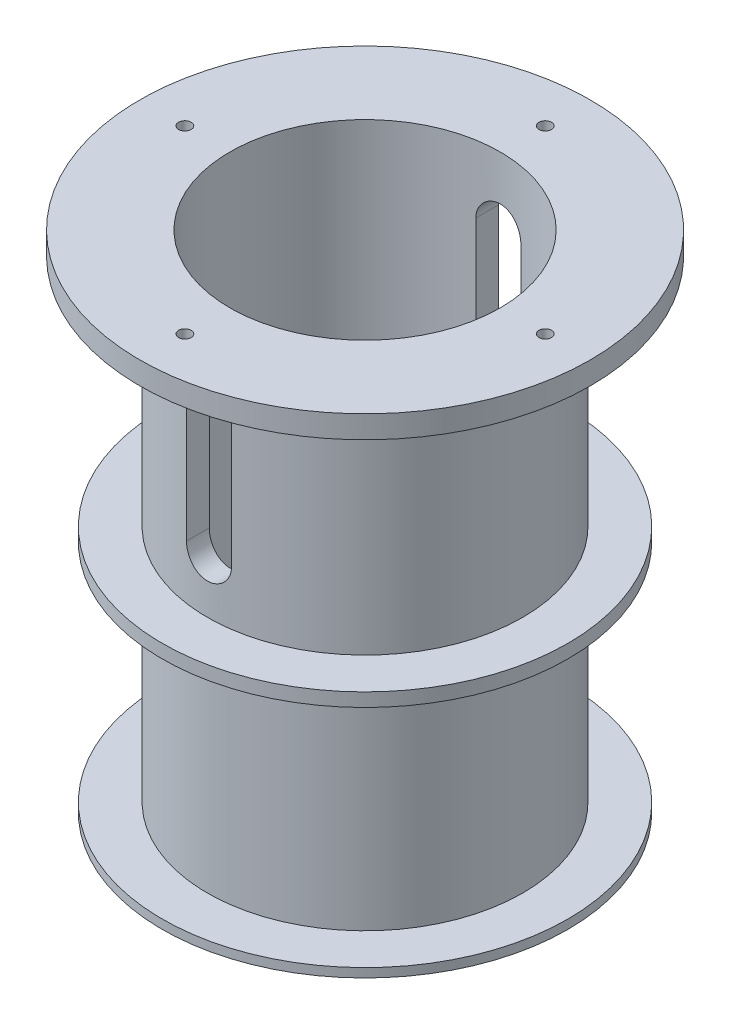
from build123d import *

# Parameters (mm, degrees)
SKETCH_2_R               = 35
SKETCH_2_R_2             = 30
EXTRUDE_1_DEPTH          = 50
SKETCH_3_R               = 45
SKETCH_3_R_2             = 30
EXTRUDE_2_DEPTH          = 2
CUT_EXTRUDE_1_REACH      = 134.454
SKETCH_4_R               = 1.4
CUT_EXTRUDE_2_DEPTH      = 93.736184955
CUT_EXTRUDE_2_DEPTH_BACK = 93.736184955


with BuildPart() as part:
    # 草图1 → 旋转1 (revolve)
    with BuildSketch(Plane.XY, mode=Mode.PRIVATE) as revolve_1_sk:
        Polygon((-45, 0), (-30, 0), (-30, 60), (-50, 60), (-50, 55), (-35, 55), (-35, 3), (-45, 3), align=None)
    revolve(revolve_1_sk.sketch.rotate(Axis((0, -563.187180309, 0), (0, 1, 0)), 180), axis=Axis((0, -563.187180309, 0), (0, 1, 0)))

    # 草图2 → 凸台-拉伸1 (add)
    with BuildSketch(Plane.XZ):
        Circle(SKETCH_2_R)
        Circle(SKETCH_2_R_2, mode=Mode.SUBTRACT)
    extrude(amount=EXTRUDE_1_DEPTH)

    # 草图3 → 凸台-拉伸2 (add)
    with BuildSketch(Plane.XZ.offset(50)):
        Circle(SKETCH_3_R)
        Circle(SKETCH_3_R_2, mode=Mode.SUBTRACT)
    extrude(amount=EXTRUDE_2_DEPTH)

    # 草图4 → 切除-拉伸1 (cut, up to next)
    with BuildSketch(Plane(origin=(0, 60, 0), x_dir=(1, 0, 0), z_dir=(0, 1, 0)), mode=Mode.PRIVATE) as cut_extrude_1_sk1:
        with Locations(Location((0, 40, 0), (0, 0, 180))):
            Circle(SKETCH_4_R)
    cut_extrude_1_tool1 = extrude(cut_extrude_1_sk1.sketch, amount=-CUT_EXTRUDE_1_REACH, mode=Mode.PRIVATE) & part.part
    # 草图4 → 切除-拉伸1 (cut, up to next)
    with BuildSketch(Plane(origin=(0, 60, 0), x_dir=(1, 0, 0), z_dir=(0, 1, 0)), mode=Mode.PRIVATE) as cut_extrude_1_sk2:
        with Locations(Location((40, 0, 0), (0, 0, 180))):
            Circle(SKETCH_4_R)
    cut_extrude_1_tool2 = extrude(cut_extrude_1_sk2.sketch, amount=-CUT_EXTRUDE_1_REACH, mode=Mode.PRIVATE) & part.part
    # 草图4 → 切除-拉伸1 (cut, up to next)
    with BuildSketch(Plane(origin=(0, 60, 0), x_dir=(1, 0, 0), z_dir=(0, 1, 0)), mode=Mode.PRIVATE) as cut_extrude_1_sk3:
        with Locations(Location((0, -40, 0), (0, 0, 180))):
            Circle(SKETCH_4_R)
    cut_extrude_1_tool3 = extrude(cut_extrude_1_sk3.sketch, amount=-CUT_EXTRUDE_1_REACH, mode=Mode.PRIVATE) & part.part
    # 草图4 → 切除-拉伸1 (cut, up to next)
    with BuildSketch(Plane(origin=(0, 60, 0), x_dir=(1, 0, 0), z_dir=(0, 1, 0)), mode=Mode.PRIVATE) as cut_extrude_1_sk4:
        with Locations(Location((-40, 0, 0), (0, 0, 180))):
            Circle(SKETCH_4_R)
    cut_extrude_1_tool4 = extrude(cut_extrude_1_sk4.sketch, amount=-CUT_EXTRUDE_1_REACH, mode=Mode.PRIVATE) & part.part
    add(cut_extrude_1_tool1.solids().sort_by_distance((0, 60, -40))[0], mode=Mode.SUBTRACT)
    add(cut_extrude_1_tool2.solids().sort_by_distance((40, 60, 0))[0], mode=Mode.SUBTRACT)
    add(cut_extrude_1_tool3.solids().sort_by_distance((0, 60, 40))[0], mode=Mode.SUBTRACT)
    add(cut_extrude_1_tool4.solids().sort_by_distance((-40, 60, 0))[0], mode=Mode.SUBTRACT)

    # 草图5 → 切除-拉伸2 (cut, two sides)
    with BuildSketch(Plane.XY) as cut_extrude_2_sk:
        with BuildLine():
            Line((5, 45), (5, 15))
            ThreePointArc((5, 15), (0, 10), (-5, 15))
            Line((-5, 15), (-5, 45))
            ThreePointArc((-5, 45), (0, 50), (5, 45))
        make_face()
    extrude(amount=CUT_EXTRUDE_2_DEPTH, mode=Mode.SUBTRACT)
    extrude(cut_extrude_2_sk.sketch, amount=-CUT_EXTRUDE_2_DEPTH_BACK, mode=Mode.SUBTRACT)


solid = part.part
